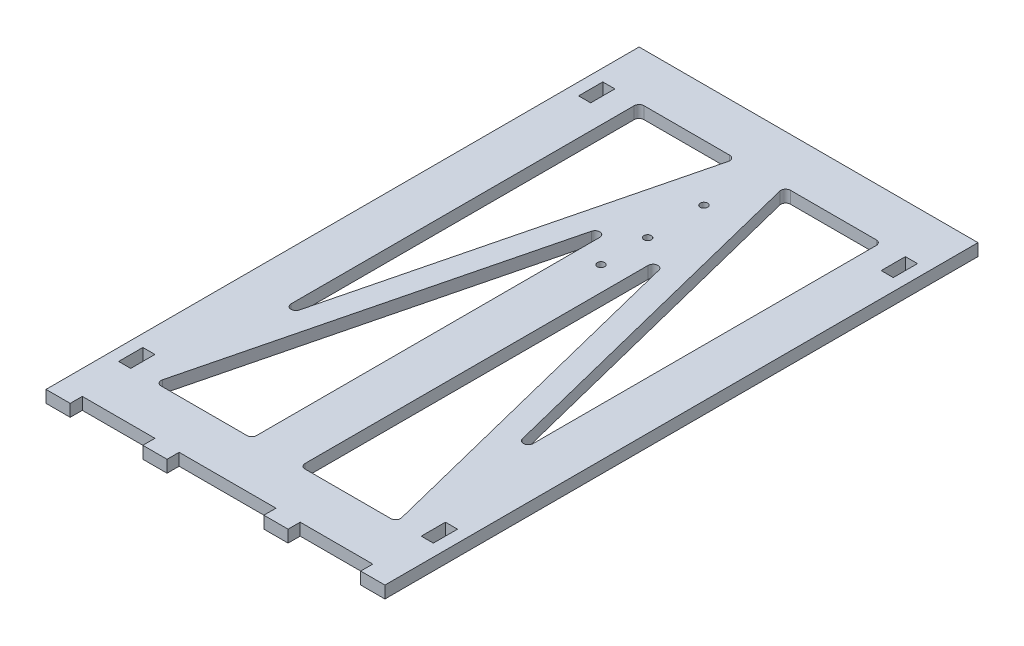
from build123d import *

# Parameters (mm, degrees)
SKETCH1_W         = 6.35
SKETCH1_H         = 12.7
SKETCH1_R         = 1.93499994
FRONT_PANEL_DEPTH = 6.35
FILLET1_R         = 2.54


with BuildPart() as part:
    # Sketch1 → Front Panel (new body)
    with BuildSketch(Plane(origin=(0, 0, 0), x_dir=(1, 0, 0), z_dir=(0, 1, 0))):
        Polygon((0, 304.8), (0, -6.35), (12.7, -6.35), (12.7, 0), (50.8, 0), (50.8, -6.35), (63.5, -6.35), (63.5, 0), (114.3, 0), (114.3, -6.35), (127, -6.35), (127, 0), (165.1, 0), (165.1, -6.35), (177.8, -6.35), (177.8, 304.8), align=None)
        with Locations((9.525, 31.75)):
            Rectangle(SKETCH1_W, SKETCH1_H, mode=Mode.SUBTRACT)
        Polygon((25.4, 25.4), (76.2, 228.6), (76.2, 25.4), align=None, mode=Mode.SUBTRACT)
        with Locations((168.275, 31.75)):
            Rectangle(SKETCH1_W, SKETCH1_H, mode=Mode.SUBTRACT)
        Polygon((101.6, 25.4), (101.6, 228.6), (152.4, 25.4), align=None, mode=Mode.SUBTRACT)
        Polygon((25.4, 279.4), (76.2, 279.4), (25.4, 76.2), align=None, mode=Mode.SUBTRACT)
        with Locations((9.525, 273.05)):
            Rectangle(SKETCH1_W, SKETCH1_H, mode=Mode.SUBTRACT)
        Polygon((152.4, 76.2), (101.6, 279.4), (152.4, 279.4), align=None, mode=Mode.SUBTRACT)
        with Locations((88.9, 195.900000122)):
            Circle(SKETCH1_R, mode=Mode.SUBTRACT)
        with Locations((88.9, 220.400000144)):
            Circle(SKETCH1_R, mode=Mode.SUBTRACT)
        with Locations((88.9, 249.900000072)):
            Circle(SKETCH1_R, mode=Mode.SUBTRACT)
        with Locations((168.275, 273.05)):
            Rectangle(SKETCH1_W, SKETCH1_H, mode=Mode.SUBTRACT)
    extrude(amount=FRONT_PANEL_DEPTH)

    # Fillet1
    fillet1_edges = [part.edges().sort_by_distance(p)[0] for p in [
        (76.2, 3.175, -25.4),
        (76.2, 3.175, -228.6),
        (25.4, 3.175, -25.4),
        (76.2, 3.175, -279.4),
        (25.4, 3.175, -279.4),
        (25.4, 3.175, -76.2),
        (152.4, 3.175, -279.4),
        (101.6, 3.175, -279.4),
        (152.4, 3.175, -76.2),
        (101.6, 3.175, -228.6),
        (101.6, 3.175, -25.4),
        (152.4, 3.175, -25.4),
    ]]
    fillet(fillet1_edges, radius=FILLET1_R)


solid = part.part
